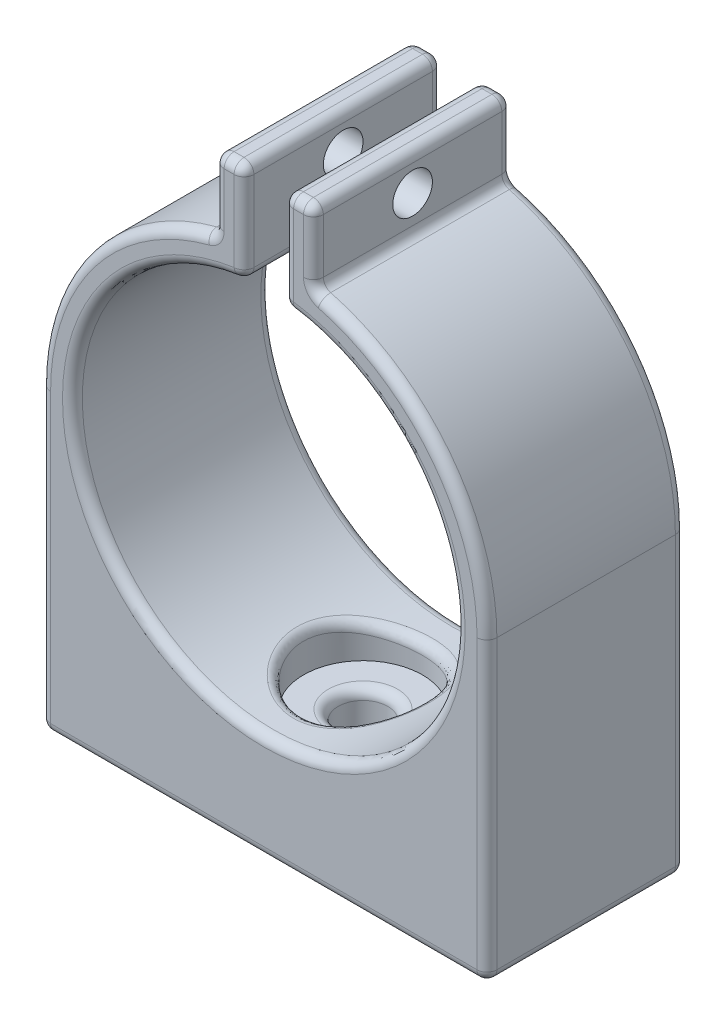
from build123d import *
from build123d.topology import SkipClean

# Parameters (mm, degrees)
BOSS_EXTRUDE1_DEPTH = 20
SKETCH6_R           = 2
CUT_EXTRUDE4_DEPTH  = 7
SKETCH7_R           = 2.5
CUT_EXTRUDE5_DEPTH  = 23
CUT_EXTRUDE6_START  = -8
SKETCH8_R           = 6
CUT_EXTRUDE6_DEPTH  = 5
FILLET5_R           = 1


with BuildPart() as part:
    # Sketch1 → Boss-Extrude1 (new body)
    with BuildSketch(Plane.XY):
        with BuildLine():
            Line((-2, 29.196093353), (-5, 29.196093353))
            Line((-5, 29.196093353), (-5, 21.937410968))
            ThreePointArc((-5, 21.937410968), (-17.589059099, 14.0312152), (-22.5, 0))
            Line((-22.5, 0), (-22.5, -16.74713815))
            Line((-22.5, -16.74713815), (-22.5, -30))
            Line((-22.5, -30), (0, -30))
            Line((0, -30), (0, -19.3))
            ThreePointArc((0, -19.3), (-19.274005833, -1.001348664), (-2, 19.196093353))
            Line((-2, 19.196093353), (-2, 29.196093353))
        make_face()
    boss_extrude1 = extrude(amount=BOSS_EXTRUDE1_DEPTH)

    # Sketch6 → Cut-Extrude4 (cut)
    with BuildSketch(Plane.ZY.offset(5)):
        with Locations((10, 25.566752161)):
            Circle(SKETCH6_R)
    cut_extrude4 = extrude(amount=-CUT_EXTRUDE4_DEPTH, mode=Mode.SUBTRACT)

    # Mirror3: Boss-Extrude1, Cut-Extrude4 across plane
    with SkipClean():  # the faces are left unmerged after this step: merging them gives an invalid solid
        add(boss_extrude1.mirror(Plane(origin=(0, -19.3, 20), x_dir=(0, 0, 1), z_dir=(-1, 0, 0))))
        add(cut_extrude4.mirror(Plane(origin=(0, -19.3, 20), x_dir=(0, 0, 1), z_dir=(-1, 0, 0))), mode=Mode.SUBTRACT)

    # Sketch7 → Cut-Extrude5 (cut)
    with SkipClean():  # the faces are left unmerged after this step: merging them gives an invalid solid
        with BuildSketch(Plane.XZ.offset(30)):
            with Locations((0, 10)):
                Circle(SKETCH7_R)
        extrude(amount=-CUT_EXTRUDE5_DEPTH, mode=Mode.SUBTRACT)

    # Sketch8 → Cut-Extrude6 (cut)
    with SkipClean():  # the faces are left unmerged after this step: merging them gives an invalid solid
        with BuildSketch(Plane(origin=(0, -30, 0), x_dir=(-1, 0, 0), z_dir=(0, -1, 0)).offset(CUT_EXTRUDE6_START)):
            with Locations((0, -10)):
                Circle(SKETCH8_R)
        extrude(amount=-CUT_EXTRUDE6_DEPTH, mode=Mode.SUBTRACT)

    # Fillet5
    fillet5_edges = [part.edges().sort_by_distance(p)[0] for p in [
        (-4.243087858, -18.827804053, 5.757806515),
        (-2.5, -22, 10),
        (1.767766953, -30, 8.232233047),
        (17.589059099, 14.0312152, 0),
        (5, 25.566752161, 0),
        (3.5, 29.196093353, 0),
        (2, 24.196093353, 0),
        (22.5, -15, 0),
        (17.589059099, 14.0312152, 20),
        (5, 25.566752161, 20),
        (3.5, 29.196093353, 20),
        (2, 24.196093353, 20),
        (22.5, -15, 20),
        (22.5, -30, 10),
        (2, 19.196093353, 10),
        (2, 29.196093353, 10),
        (5, 29.196093353, 10),
        (5, 21.937410968, 10),
        (-17.589059099, 14.0312152, 0),
        (-22.5, -15, 0),
        (-11.25, -30, 0),
        (-19.274005833, -1.001348664, 0),
        (-2, 24.196093353, 0),
        (-3.5, 29.196093353, 0),
        (-5, 25.566752161, 0),
        (-22.5, -15, 20),
        (-11.25, -30, 20),
        (-19.274005833, -1.001348664, 20),
        (-2, 24.196093353, 20),
        (-3.5, 29.196093353, 20),
        (-5, 25.566752161, 20),
        (-5, 21.937410968, 10),
        (-5, 29.196093353, 10),
        (-2, 29.196093353, 10),
        (-2, 19.196093353, 10),
        (-22.5, -30, 10),
        (-17.589059099, 14.0312152, 20),
    ]]
    fillet(fillet5_edges, radius=FILLET5_R)


solid = part.part
